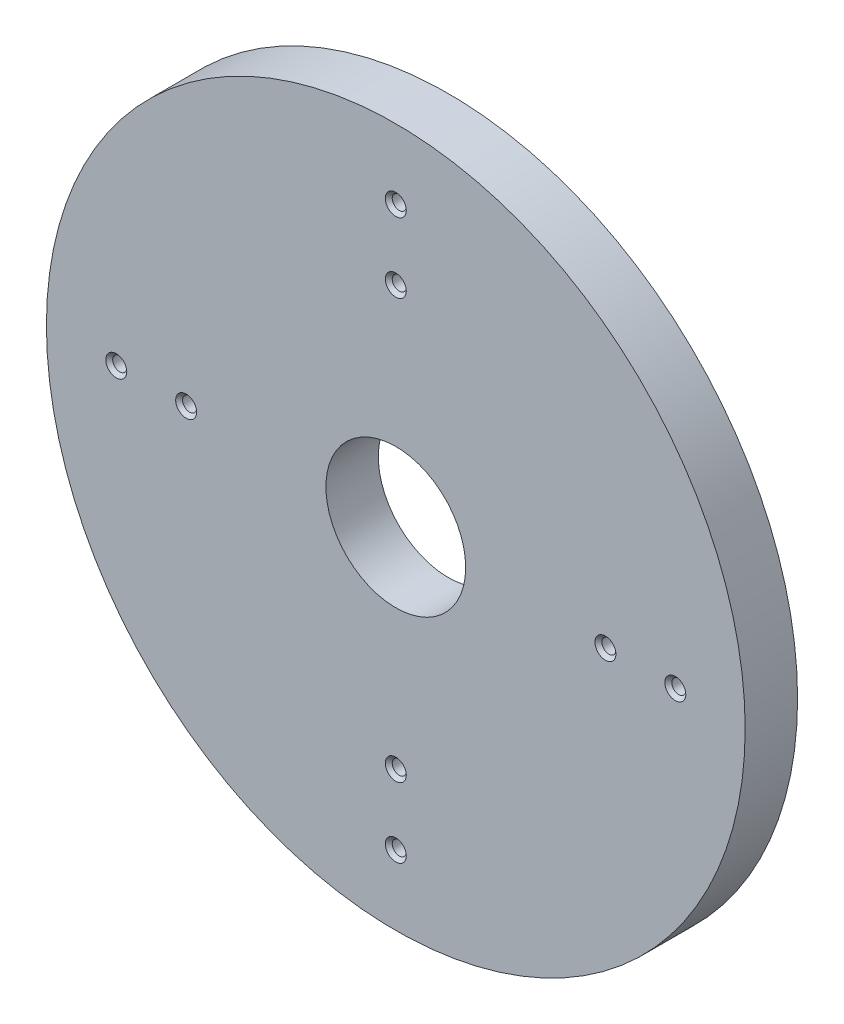
from build123d import *

# Parameters (mm, degrees)
SKETCH1_R                        = 127
SKETCH1_R_2                      = 25.4
BOSS_EXTRUDE2_DEPTH              = 19.05
F_1_4_20_TAPPED_HOLE1_AT_2_COUNT = 2
F_1_4_20_TAPPED_HOLE1_AT_2_PITCH = 127
F_1_4_20_TAPPED_HOLE1_AT_3_COUNT = 2
F_1_4_20_TAPPED_HOLE1_AT_3_PITCH = 107.763073453
F_1_4_20_TAPPED_HOLE1_AT_4_COUNT = 2
F_1_4_20_TAPPED_HOLE1_AT_4_PITCH = 177.8
F_1_4_20_TAPPED_HOLE1_AT_5_COUNT = 2
F_1_4_20_TAPPED_HOLE1_AT_5_PITCH = 152.4
F_1_4_20_TAPPED_HOLE1_AT_6_COUNT = 2
F_1_4_20_TAPPED_HOLE1_AT_6_PITCH = 127
F_1_4_20_TAPPED_HOLE1_AT_7_COUNT = 2
F_1_4_20_TAPPED_HOLE1_AT_7_PITCH = 107.763073453
F_1_4_20_TAPPED_HOLE1_AT_8_COUNT = 2
F_1_4_20_TAPPED_HOLE1_AT_8_PITCH = 25.4


with BuildPart() as part:
    # Sketch1 → Boss-Extrude2 (new body)
    with BuildSketch(Plane.XY):
        Circle(SKETCH1_R)
        Circle(SKETCH1_R_2, mode=Mode.SUBTRACT)
    extrude(amount=BOSS_EXTRUDE2_DEPTH)

    # Sketch5 → 1/4-20 Tapped Hole1 (revolve, cut)
    with BuildSketch(Plane(origin=(-76.2, 0, 19.05), x_dir=(0, -1, 0), z_dir=(1, 0, 0))):
        Polygon((0, 0), (0, 19.05), (3.81, 19.05), (2.5527, 17.7927), (2.5527, 1.2573), (3.81, 0), align=None)
    f_1_4_20_tapped_hole1 = revolve(axis=Axis((-76.2, 0, 25.4), (0, 0, -1)), mode=Mode.SUBTRACT)

    # 1/4-20 Tapped Hole1 at 2: 1/4-20 Tapped Hole1 ×2
    with Locations(*[Vector(0.6, 0.8, 0) * (i * F_1_4_20_TAPPED_HOLE1_AT_2_PITCH) for i in range(1, F_1_4_20_TAPPED_HOLE1_AT_2_COUNT)]):
        add(f_1_4_20_tapped_hole1, mode=Mode.SUBTRACT)

    # 1/4-20 Tapped Hole1 at 3: 1/4-20 Tapped Hole1 ×2
    with Locations(*[Vector(0.707106781, 0.707106781, 0) * (i * F_1_4_20_TAPPED_HOLE1_AT_3_PITCH) for i in range(1, F_1_4_20_TAPPED_HOLE1_AT_3_COUNT)]):
        add(f_1_4_20_tapped_hole1, mode=Mode.SUBTRACT)

    # 1/4-20 Tapped Hole1 at 4: 1/4-20 Tapped Hole1 ×2
    with Locations(*[(i * F_1_4_20_TAPPED_HOLE1_AT_4_PITCH, 0, 0) for i in range(1, F_1_4_20_TAPPED_HOLE1_AT_4_COUNT)]):
        add(f_1_4_20_tapped_hole1, mode=Mode.SUBTRACT)

    # 1/4-20 Tapped Hole1 at 5: 1/4-20 Tapped Hole1 ×2
    with Locations(*[(i * F_1_4_20_TAPPED_HOLE1_AT_5_PITCH, 0, 0) for i in range(1, F_1_4_20_TAPPED_HOLE1_AT_5_COUNT)]):
        add(f_1_4_20_tapped_hole1, mode=Mode.SUBTRACT)

    # 1/4-20 Tapped Hole1 at 6: 1/4-20 Tapped Hole1 ×2
    with Locations(*[Vector(0.6, -0.8, 0) * (i * F_1_4_20_TAPPED_HOLE1_AT_6_PITCH) for i in range(1, F_1_4_20_TAPPED_HOLE1_AT_6_COUNT)]):
        add(f_1_4_20_tapped_hole1, mode=Mode.SUBTRACT)

    # 1/4-20 Tapped Hole1 at 7: 1/4-20 Tapped Hole1 ×2
    with Locations(*[Vector(0.707106781, -0.707106781, 0) * (i * F_1_4_20_TAPPED_HOLE1_AT_7_PITCH) for i in range(1, F_1_4_20_TAPPED_HOLE1_AT_7_COUNT)]):
        add(f_1_4_20_tapped_hole1, mode=Mode.SUBTRACT)

    # 1/4-20 Tapped Hole1 at 8: 1/4-20 Tapped Hole1 ×2
    with Locations(*[(-i * F_1_4_20_TAPPED_HOLE1_AT_8_PITCH, 0, 0) for i in range(1, F_1_4_20_TAPPED_HOLE1_AT_8_COUNT)]):
        add(f_1_4_20_tapped_hole1, mode=Mode.SUBTRACT)


solid = part.part
